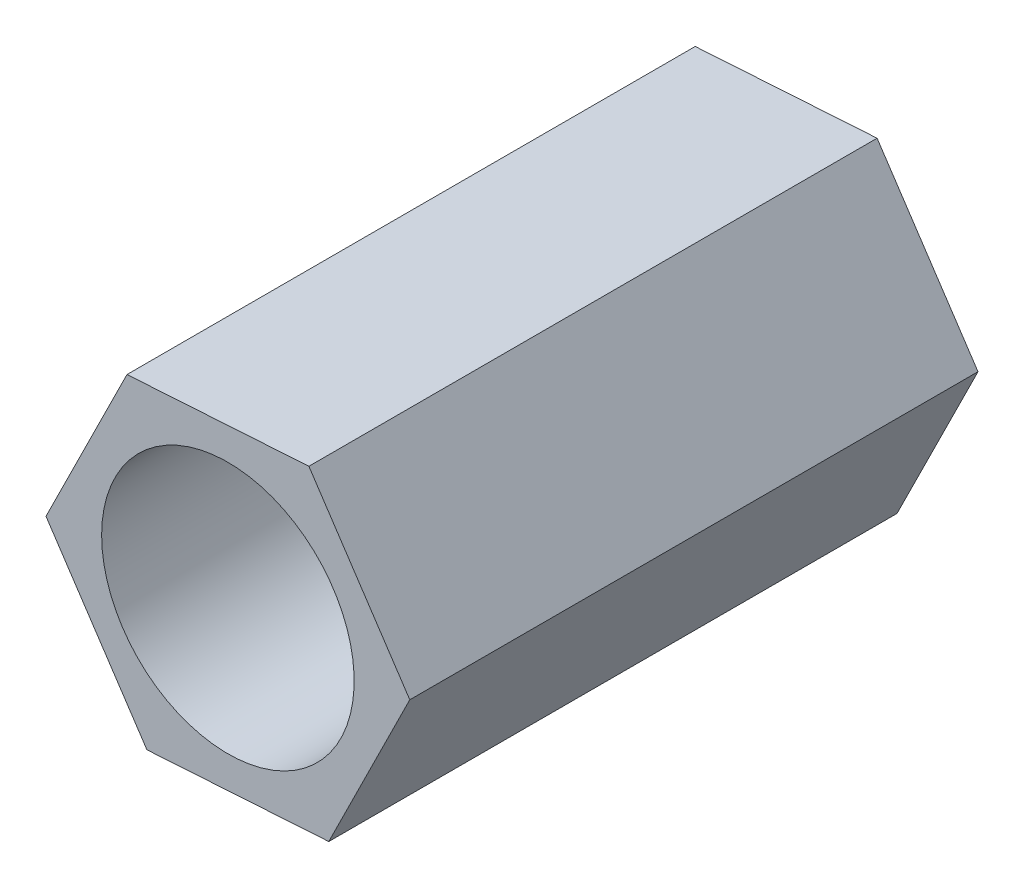
from build123d import *

# Parameters (mm, degrees)
EXTRUDE_1_DEPTH     = 9
SKETCH_2_R          = 2
CUT_EXTRUDE_1_DEPTH = 10


with BuildPart() as part:
    # 草图1 → 凸台-拉伸1 (new body)
    with BuildSketch(Plane.XY):
        Polygon((1.28284299, 2.586048568), (-1.59816226, 2.403998903), (-2.88100525, -0.182049665), (-1.28284299, -2.586048568), (1.59816226, -2.403998903), (2.88100525, 0.182049665), align=None)
    extrude(amount=EXTRUDE_1_DEPTH)

    # 草图2 → 切除-拉伸1 (cut, through all)
    with BuildSketch(Plane(origin=(0, 0, 0), x_dir=(-1, 0, 0), z_dir=(0, 0, -1))):
        Circle(SKETCH_2_R)
    extrude(amount=-CUT_EXTRUDE_1_DEPTH, mode=Mode.SUBTRACT)


solid = part.part
